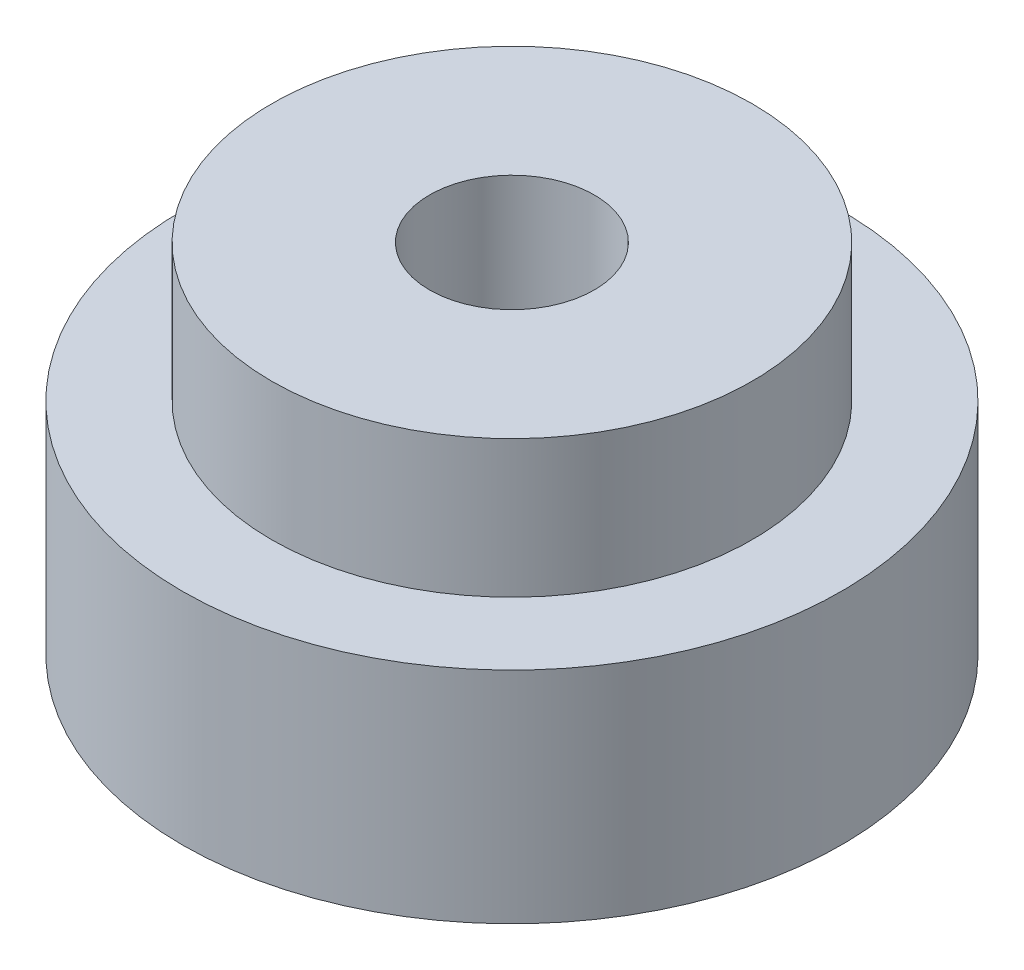
from build123d import *

# Parameters (mm, degrees)
SKETCH1_R           = 24
BOSS_EXTRUDE1_DEPTH = 16
SKETCH2_R           = 17.5
BOSS_EXTRUDE2_DEPTH = 10
SKETCH3_R           = 6
CUT_EXTRUDE1_DEPTH  = 26


with BuildPart() as part:
    # Sketch1 → Boss-Extrude1 (new body)
    with BuildSketch(Plane(origin=(0, 0, 0), x_dir=(1, 0, 0), z_dir=(0, 1, 0))):
        Circle(SKETCH1_R)
    extrude(amount=BOSS_EXTRUDE1_DEPTH)

    # Sketch2 → Boss-Extrude2 (add)
    with BuildSketch(Plane(origin=(0, 16, 0), x_dir=(1, 0, 0), z_dir=(0, 1, 0))):
        Circle(SKETCH2_R)
    extrude(amount=BOSS_EXTRUDE2_DEPTH)

    # Sketch3 → Cut-Extrude1 (cut)
    with BuildSketch(Plane(origin=(0, 26, 0), x_dir=(1, 0, 0), z_dir=(0, 1, 0))):
        Circle(SKETCH3_R)
    extrude(amount=-CUT_EXTRUDE1_DEPTH, mode=Mode.SUBTRACT)


solid = part.part
